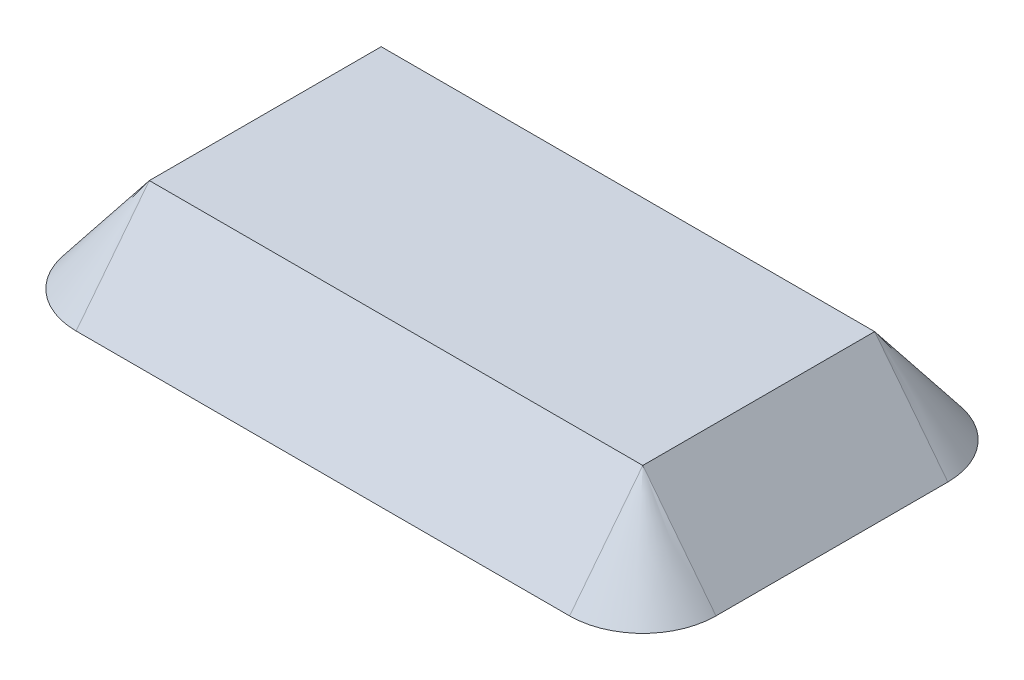
from build123d import *

# Parameters (mm, degrees)
CROQUIS1_W               = 207.5
CROQUIS1_H               = 97.5
CROQUIS1_W_2             = 204.5
CROQUIS1_H_2             = 94.5
SALIENTE_EXTRUIR1_DEPTH  = 25
CROQUIS2_W               = 207.5
CROQUIS2_H               = 97.5
SALIENTE_EXTRUIR2_DEPTH  = 3
SALIENTE_EXTRUIR3_DEPTH  = 207.5
SALIENTE_EXTRUIR4_DEPTH  = 97.5
REVOLUCI_N1_ANGLE        = 90
REVOLUCI_N2_ANGLE        = 90
REVOLUCI_N3_ANGLE        = 90
REVOLUCI_N4_ANGLE        = 90
SALIENTE_EXTRUIR5_DEPTH  = 97.5
CROQUIS10_W              = 2.5
CROQUIS10_H              = 19
SALIENTE_EXTRUIR6_DEPTH  = 204.5
CROQUIS11_W              = 2.5
CROQUIS11_H              = 19
SALIENTE_EXTRUIR7_DEPTH  = 204.5
CROQUIS13_R              = 10
SALIENTE_EXTRUIR8_DEPTH  = 0.3
CROQUIS14_R              = 10
SALIENTE_EXTRUIR9_DEPTH  = 1.5
CROQUIS15_W              = 20
CROQUIS15_H              = 20
SALIENTE_EXTRUIR10_DEPTH = 1.5
SALIENTE_EXTRUIR11_DEPTH = 1.5
CROQUIS17_R              = 10
SALIENTE_EXTRUIR12_DEPTH = 0.3
CROQUIS18_R              = 10
SALIENTE_EXTRUIR13_DEPTH = 1.5
CROQUIS19_R              = 10
SALIENTE_EXTRUIR14_DEPTH = 1.5


with BuildPart() as part:
    # Croquis1 → Saliente-Extruir1 (new body)
    with BuildSketch(Plane(origin=(0, 0, 0), x_dir=(1, 0, 0), z_dir=(0, 1, 0))):
        Rectangle(CROQUIS1_W, CROQUIS1_H)
        Rectangle(CROQUIS1_W_2, CROQUIS1_H_2, mode=Mode.SUBTRACT)
    extrude(amount=SALIENTE_EXTRUIR1_DEPTH)

    # Croquis2 → Saliente-Extruir2 (add)
    with BuildSketch(Plane(origin=(0, 25, 0), x_dir=(1, 0, 0), z_dir=(0, 1, 0))):
        Rectangle(CROQUIS2_W, CROQUIS2_H)
    extrude(amount=SALIENTE_EXTRUIR2_DEPTH)

    # Croquis3 → Saliente-Extruir3 (add)
    with BuildSketch(Plane.ZY.offset(103.75)):
        Polygon((48.75, 28), (79.533073766, -11.40053768), (78.033073766, -11.40053768), (48.75, 26.080087552), align=None)
        Polygon((-48.75, 28), (-79.533073766, -11.40053768), (-78.033073766, -11.40053768), (-48.75, 26.080087552), align=None)
    extrude(amount=-SALIENTE_EXTRUIR3_DEPTH)

    # Croquis4 → Saliente-Extruir4 (add)
    with BuildSketch(Plane.XY.offset(48.75)):
        Polygon((-103.75, 28), (-134.533073766, -11.40053768), (-133.033073766, -11.40053768), (-102.25, 28), align=None)
    extrude(amount=-SALIENTE_EXTRUIR4_DEPTH)

    # Croquis5 → Revolución1 (revolve)
    with BuildSketch(Plane.XY.offset(48.75)):
        Polygon((-103.75, 28), (-134.533073766, -11.40053768), (-133.033073766, -11.40053768), (-103.75, 26.080087552), align=None)
    revolve(axis=Axis((-103.75, 26.080087552, 48.75), (0, 1, 0)), revolution_arc=REVOLUCI_N1_ANGLE)

    # Croquis6 → Revolución2 (revolve)
    with BuildSketch(Plane.ZY.offset(103.75)):
        Polygon((-48.75, 28), (-79.533073766, -11.40053768), (-78.033073766, -11.40053768), (-48.75, 26.080087552), align=None)
    revolve(axis=Axis((-103.75, 26.080087552, -48.75), (0, 1, 0)), revolution_arc=REVOLUCI_N2_ANGLE)

    # Croquis7 → Revolución3 (revolve)
    with BuildSketch(Plane(origin=(103.75, 0, 0), x_dir=(0, 0, -1), z_dir=(1, 0, 0))):
        Polygon((48.75, 26.080087552), (48.75, 28), (79.533073766, -11.40053768), (78.033073766, -11.40053768), align=None)
    revolve(axis=Axis((103.75, 26.080087552, -48.75), (0, -1, 0)), revolution_arc=REVOLUCI_N3_ANGLE)

    # Croquis8 → Revolución4 (revolve)
    with BuildSketch(Plane(origin=(103.75, 0, 0), x_dir=(0, 0, -1), z_dir=(1, 0, 0))):
        Polygon((-48.75, 28), (-79.533073766, -11.40053768), (-78.033073766, -11.40053768), (-48.75, 26.080087552), align=None)
    revolve(axis=Axis((103.75, 26.080087552, 48.75), (0, 1, 0)), revolution_arc=REVOLUCI_N4_ANGLE)

    # Croquis9 → Saliente-Extruir5 (add)
    with BuildSketch(Plane(origin=(0, 0, 48.75), x_dir=(-1, 0, 0), z_dir=(0, 0, -1))):
        Polygon((-103.75, 28), (-103.75, 26.080087552), (-133.033073766, -11.40053768), (-134.533073766, -11.40053768), align=None)
    extrude(amount=SALIENTE_EXTRUIR5_DEPTH)

    # Croquis10 → Saliente-Extruir6 (add)
    with BuildSketch(Plane.ZY.offset(-102.25)):
        with Locations((46, 15.5)):
            Rectangle(CROQUIS10_W, CROQUIS10_H)
    extrude(amount=SALIENTE_EXTRUIR6_DEPTH)

    # Croquis11 → Saliente-Extruir7 (add)
    with BuildSketch(Plane.ZY.offset(-102.25)):
        with Locations((-46, 15.5)):
            Rectangle(CROQUIS11_W, CROQUIS11_H)
    extrude(amount=SALIENTE_EXTRUIR7_DEPTH)



with BuildPart() as body_2:
    # Croquis13 → Saliente-Extruir8 (new body)
    with BuildSketch(Plane(origin=(-102.25, 0, 0), x_dir=(0, 0, -1), z_dir=(1, 0, 0))):
        with Locations((0, -10)):
            Circle(CROQUIS13_R)
    extrude(amount=SALIENTE_EXTRUIR8_DEPTH)

    # Croquis14 → Saliente-Extruir9 (add)
    with BuildSketch(Plane.ZY.offset(102.25)):
        with Locations((0, -10)):
            Circle(CROQUIS14_R)
    extrude(amount=SALIENTE_EXTRUIR9_DEPTH)


with BuildPart() as part_1:
    add(part.part)

    add(body_2.part)  # Saliente-Extruir10 merges body 2
    # Croquis15 → Saliente-Extruir10 (add)
    with BuildSketch(Plane.ZY.offset(103.75)):
        Rectangle(CROQUIS15_W, CROQUIS15_H)
    extrude(amount=-SALIENTE_EXTRUIR10_DEPTH)

    # Croquis16 → Saliente-Extruir11 (add)
    with BuildSketch(Plane.ZY.offset(-102.25)):
        with BuildLine():
            Line((10, -10), (0, -10))
            Line((0, -10), (-10, -10))
            ThreePointArc((-10, -10), (0, -20), (10, -10))
        make_face()
        with BuildLine():
            ThreePointArc((10, -10), (7.071067812, -2.928932188), (0, 0))
            Line((0, 0), (0, -10))
            Line((0, -10), (10, -10))
        make_face()
        with BuildLine():
            Line((0, -10), (0, 0))
            ThreePointArc((0, 0), (-7.071067812, -2.928932188), (-10, -10))
            Line((-10, -10), (0, -10))
        make_face()
        with BuildLine():
            ThreePointArc((-10, -10), (-7.071067812, -2.928932188), (0, 0))
            Line((0, 0), (-10, 0))
            Line((-10, 0), (-10, -10))
        make_face()
        with BuildLine():
            Line((10, 0), (0, 0))
            ThreePointArc((0, 0), (7.071067812, -2.928932188), (10, -10))
            Line((10, -10), (10, 0))
        make_face()
        Polygon((-10, 0), (0, 0), (10, 0), (10, 10), (-10, 10), align=None)
    extrude(amount=-SALIENTE_EXTRUIR11_DEPTH)

    # Croquis17 → Saliente-Extruir12 (add)
    with BuildSketch(Plane.ZY.offset(-102.25)):
        with Locations((0, -10)):
            Circle(CROQUIS17_R)
    extrude(amount=SALIENTE_EXTRUIR12_DEPTH)

    # Croquis18 → Saliente-Extruir13 (add)
    with BuildSketch(Plane.ZY.offset(-101.95)):
        with Locations((0, -10)):
            Circle(CROQUIS18_R)
    extrude(amount=SALIENTE_EXTRUIR13_DEPTH)

    # Croquis19 → Saliente-Extruir14 (add)
    with BuildSketch(Plane(origin=(-101.95, 0, 0), x_dir=(0, 0, -1), z_dir=(1, 0, 0))):
        with Locations((0, -10)):
            Circle(CROQUIS19_R)
    extrude(amount=SALIENTE_EXTRUIR14_DEPTH)


solid = part_1.part
